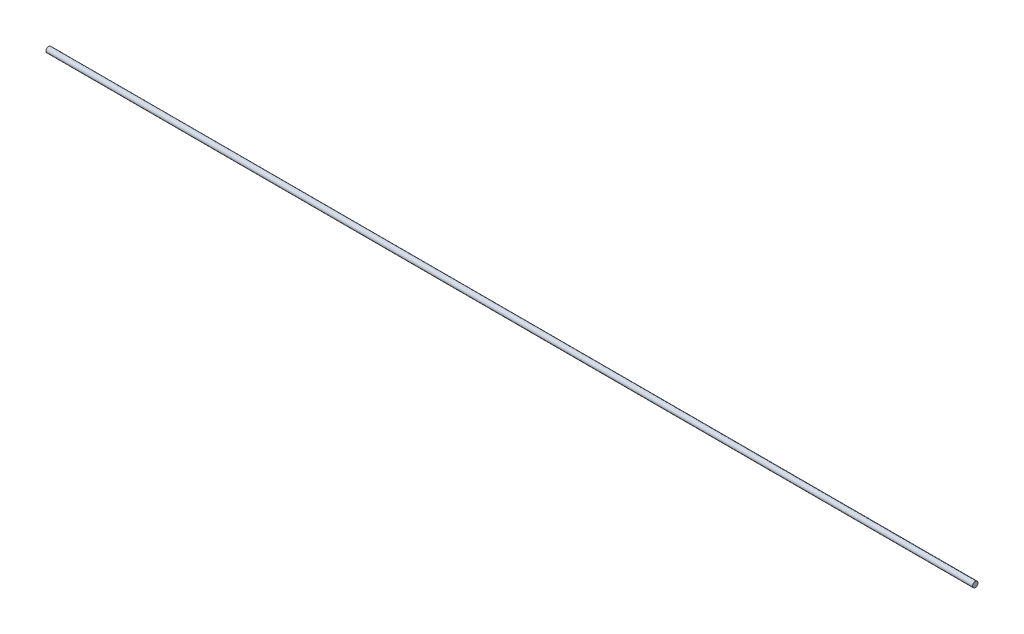
from build123d import *

# Parameters (mm, degrees)
SKETCH1_R           = 3
SKETCH1_R_2         = 0.003
BOSS_EXTRUDE1_DEPTH = 511


with BuildPart() as part:
    # Sketch1 → Boss-Extrude1 (new body, symmetric)
    with BuildSketch(Plane(origin=(0, 0, 0), x_dir=(0, 0, -1), z_dir=(1, 0, 0))):
        Circle(SKETCH1_R)
        Circle(SKETCH1_R_2, mode=Mode.SUBTRACT)
    extrude(amount=BOSS_EXTRUDE1_DEPTH, both=True)


solid = part.part
